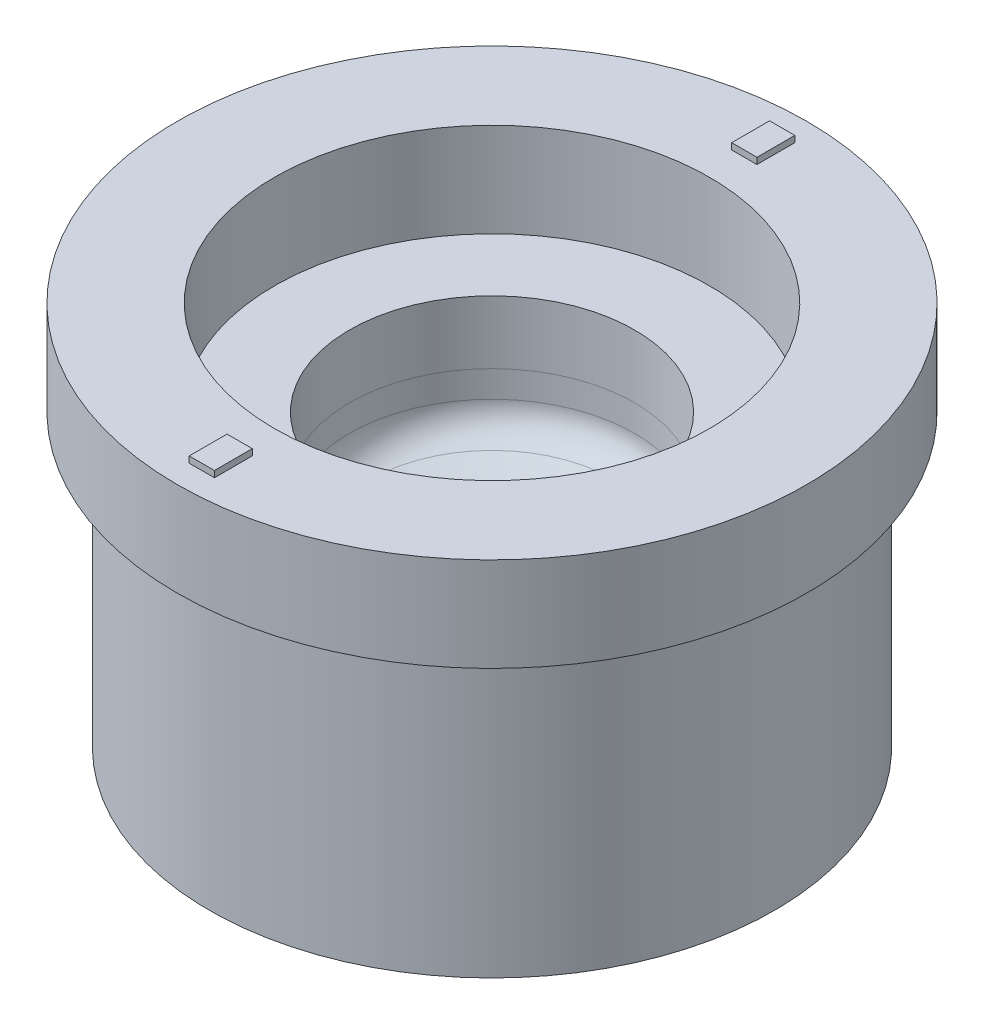
from build123d import *

# Parameters (mm, degrees)
SKETCH3_W           = 44.79
SKETCH3_H           = 46
SKETCH4_R           = 22.6
CUT_EXTRUDE1_DEPTH  = 10
SKETCH5_R           = 37
SKETCH5_R_2         = 35
CUT_EXTRUDE3_DEPTH  = 10
SKETCH6_R           = 49.89
SKETCH6_R_2         = 34.5
BOSS_EXTRUDE2_DEPTH = 14.9
SKETCH15_W          = 4
SKETCH15_H          = 6
BOSS_EXTRUDE4_DEPTH = 1
CIRPATTERN2_COUNT   = 2


with BuildPart() as part:
    # Sketch3 → Revolve1 (revolve)
    with BuildSketch(Plane.XY, mode=Mode.PRIVATE) as revolve1_sk:
        with Locations((22.395, 23)):
            Rectangle(SKETCH3_W, SKETCH3_H)
    revolve(revolve1_sk.sketch.rotate(Axis((0, -20, 0), (0, 1, 0)), 90), axis=Axis((0, -20, 0), (0, 1, 0)))

    # Sketch4 → Cut-Extrude1 (cut)
    with BuildSketch(Plane(origin=(0, 46, 0), x_dir=(1, 0, 0), z_dir=(0, 1, 0))):
        with Locations(Location((0, 0, 0), (0, 0, 270))):
            Circle(SKETCH4_R)
    extrude(amount=-CUT_EXTRUDE1_DEPTH, mode=Mode.SUBTRACT)

    # Sketch5 → Cut-Extrude3 (cut)
    with BuildSketch(Plane(origin=(0, 46, 0), x_dir=(1, 0, 0), z_dir=(0, 1, 0))):
        with Locations(Location((0, 0, 0), (0, 0, 270))):
            Circle(SKETCH5_R)
        with Locations(Location((0, 0, 0), (0, 0, 270))):
            Circle(SKETCH5_R_2, mode=Mode.SUBTRACT)
    extrude(amount=-CUT_EXTRUDE3_DEPTH, mode=Mode.SUBTRACT)

    # Sketch13 → Cut-Revolve1 (revolve, cut)
    with BuildSketch(Plane.XY, mode=Mode.PRIVATE) as cut_revolve1_sk:
        with BuildLine():
            Line((0, 36), (-22.60379982, 36))
            Line((-22.60379982, 36), (-22.60379982, 31.8))
            ThreePointArc((-22.60379982, 31.8), (-21.699560041, 28.932117818), (-19.313900536, 27.101536896))
            Line((-19.313900536, 27.101536896), (-1.342020143, 20.560307379))
            ThreePointArc((-1.342020143, 20.560307379), (-0.426423564, 20.680847956), (0, 21.5))
            Line((0, 21.5), (0, 36))
        make_face()
    revolve(cut_revolve1_sk.sketch.rotate(Axis((0, 42.388918631, 0), (0, -1, 0)), 270), axis=Axis((0, 42.388918631, 0), (0, -1, 0)), mode=Mode.SUBTRACT)


with BuildPart() as body_2:
    # Sketch6 → Boss-Extrude2 (new body)
    with BuildSketch(Plane(origin=(0, 61, 0), x_dir=(1, 0, 0), z_dir=(0, 1, 0))):
        with Locations(Location((0, 0, 0), (0, 0, 270))):
            Circle(SKETCH6_R)
        with Locations(Location((0, 0, 0), (0, 0, 270))):
            Circle(SKETCH6_R_2, mode=Mode.SUBTRACT)
    extrude(amount=-BOSS_EXTRUDE2_DEPTH)

    # Sketch15 → Boss-Extrude4 (add)
    with BuildSketch(Plane(origin=(0, 61, 0), x_dir=(1, 0, 0), z_dir=(0, 1, 0))):
        with Locations((0, -43)):
            Rectangle(SKETCH15_W, SKETCH15_H)
    boss_extrude4 = extrude(amount=BOSS_EXTRUDE4_DEPTH)

    # CirPattern2: Boss-Extrude4 ×2 about axis
    cirpattern2_axis = Axis((0, 0, 0), (0, 1, 0))
    for i in range(1, CIRPATTERN2_COUNT):
        add(boss_extrude4.rotate(cirpattern2_axis, i * 360 / CIRPATTERN2_COUNT))


solid = Compound([part.part, body_2.part])
